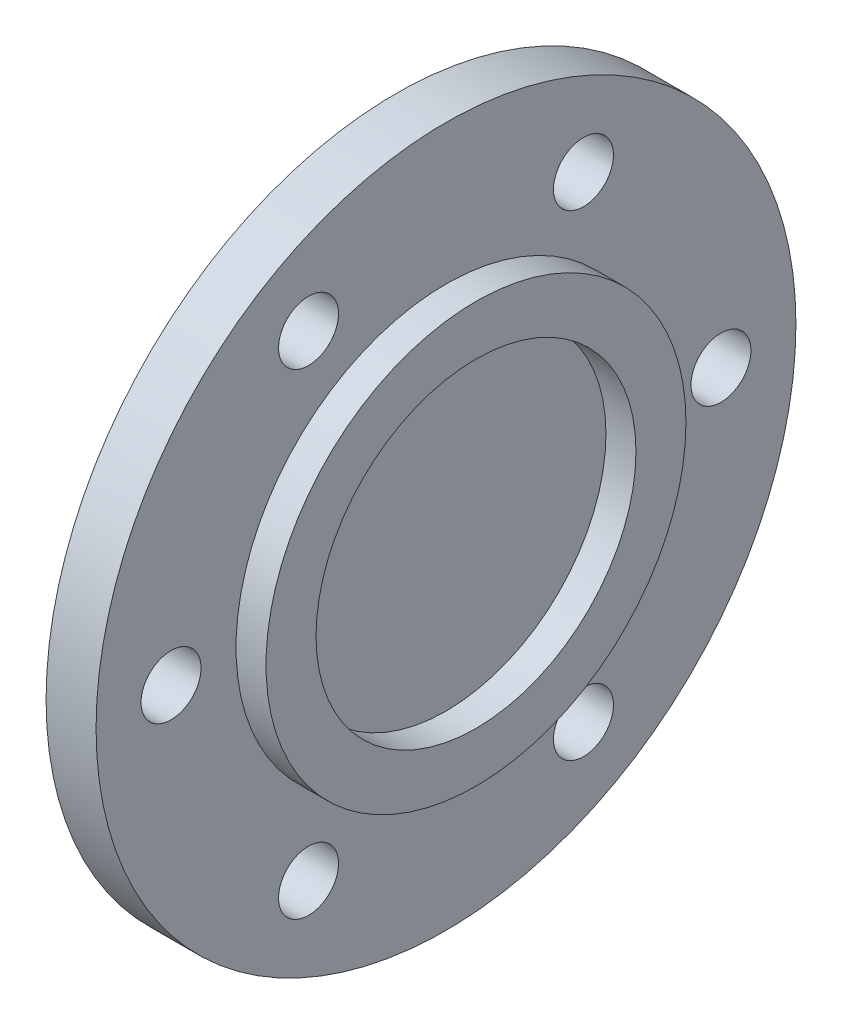
from build123d import *

# Parameters (mm, degrees)
SKETCH2_R          = 3
CUT_EXTRUDE1_DEPTH = 10
CIRPATTERN1_COUNT  = 6


with BuildPart() as part:
    # Sketch1 → Revolve1 (revolve)
    with BuildSketch(Plane.XY):
        Polygon((0, 35), (5, 35), (5, 21), (8, 21), (8, 16), (5, 16), (5, 0), (0, 0), align=None)
    revolve(axis=Axis((5, 0, 0), (-1, 0, 0)))

    # Sketch2 → Cut-Extrude1 (cut)
    with BuildSketch(Plane(origin=(5, 0, 0), x_dir=(0, 0, -1), z_dir=(1, 0, 0))):
        with Locations((27.5, 0)):
            Circle(SKETCH2_R)
    cut_extrude1 = extrude(amount=-CUT_EXTRUDE1_DEPTH, mode=Mode.SUBTRACT)

    # CirPattern1: Cut-Extrude1 ×6 about axis
    cirpattern1_axis = Axis((0, 0, 0), (1, 0, 0))
    for i in range(1, CIRPATTERN1_COUNT):
        add(cut_extrude1.rotate(cirpattern1_axis, i * 360 / CIRPATTERN1_COUNT), mode=Mode.SUBTRACT)


solid = part.part
